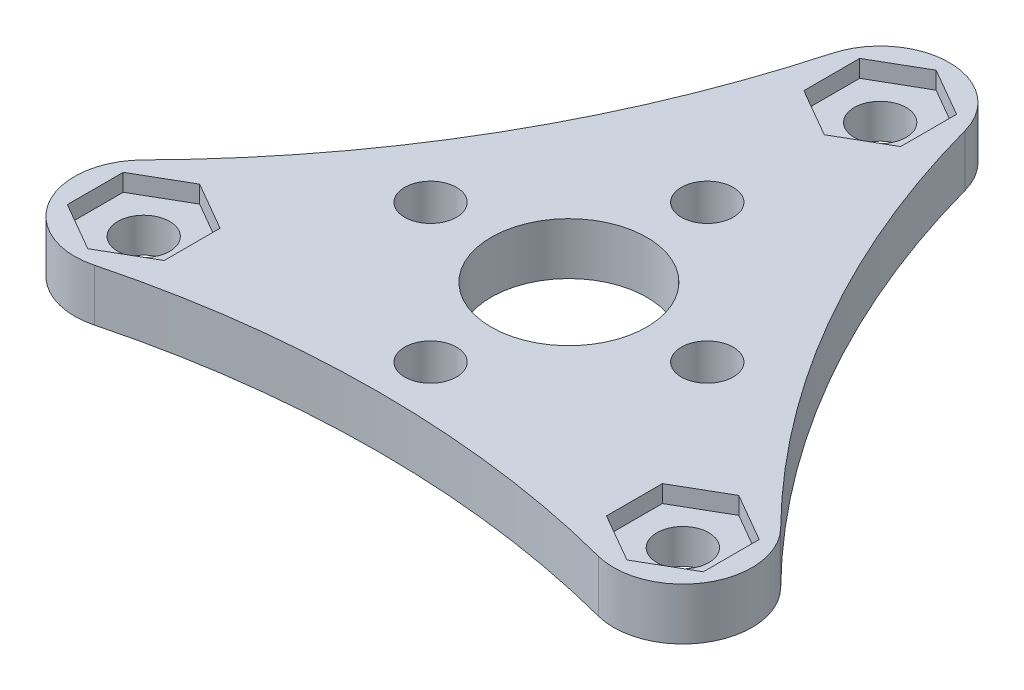
from build123d import *

# Parameters (mm, degrees)
SKETCH_1_R          = 1.5
SKETCH_1_R_2        = 4.5
EXTRUDE_1_DEPTH     = 3
CUT_EXTRUDE_1_DEPTH = 1


with BuildPart() as part:
    # 草图1 → 凸台-拉伸1 (new body)
    with BuildSketch(Plane(origin=(0, 0, 0), x_dir=(1, 0, 0), z_dir=(0, 1, 0))):
        with BuildLine():
            ThreePointArc((3.85699385, 19.059999265), (0, 22), (-3.85699385, 19.059999265))
            ThreePointArc((-3.85699385, 19.059999265), (-9.524981738, 5.499250771), (-18.434940485, -6.189744976))
            ThreePointArc((-18.434940485, -6.189744976), (-19.052558883, -11), (-14.577946635, -12.870254289))
            ThreePointArc((-14.577946635, -12.870254289), (0, -10.998501541), (14.577946635, -12.870254289))
            ThreePointArc((14.577946635, -12.870254289), (19.052558883, -11), (18.434940485, -6.189744976))
            ThreePointArc((18.434940485, -6.189744976), (9.524981738, 5.499250771), (3.85699385, 19.059999265))
        make_face()
        with Locations((8, 0)):
            Circle(SKETCH_1_R, mode=Mode.SUBTRACT)
        with Locations((0, -8)):
            Circle(SKETCH_1_R, mode=Mode.SUBTRACT)
        with Locations((-8, 0)):
            Circle(SKETCH_1_R, mode=Mode.SUBTRACT)
        with Locations((0, 8)):
            Circle(SKETCH_1_R, mode=Mode.SUBTRACT)
        with Locations((0, 18)):
            Circle(SKETCH_1_R, mode=Mode.SUBTRACT)
        with Locations((15.588457268, -9)):
            Circle(SKETCH_1_R, mode=Mode.SUBTRACT)
        with Locations((-15.588457268, -9)):
            Circle(SKETCH_1_R, mode=Mode.SUBTRACT)
        Circle(SKETCH_1_R_2, mode=Mode.SUBTRACT)
    extrude(amount=EXTRUDE_1_DEPTH)

    # 草图2 → 切除-拉伸1 (cut)
    with BuildSketch(Plane(origin=(0, 3, 0), x_dir=(1, 0, 0), z_dir=(0, 1, 0))):
        Polygon((0, 14.766838493), (2.8, 16.383419246), (2.8, 19.616580754), (0, 21.233161507), (-2.8, 19.616580754), (-2.8, 16.383419246), align=None)
        Polygon((12.788457268, -7.383419246), (12.788457268, -10.616580754), (15.588457268, -12.233161507), (18.388457268, -10.616580754), (18.388457268, -7.383419246), (15.588457268, -5.766838493), align=None)
        Polygon((-12.788457268, -7.383419246), (-15.588457268, -5.766838493), (-18.388457268, -7.383419246), (-18.388457268, -10.616580754), (-15.588457268, -12.233161507), (-12.788457268, -10.616580754), align=None)
    extrude(amount=-CUT_EXTRUDE_1_DEPTH, mode=Mode.SUBTRACT)


solid = part.part
